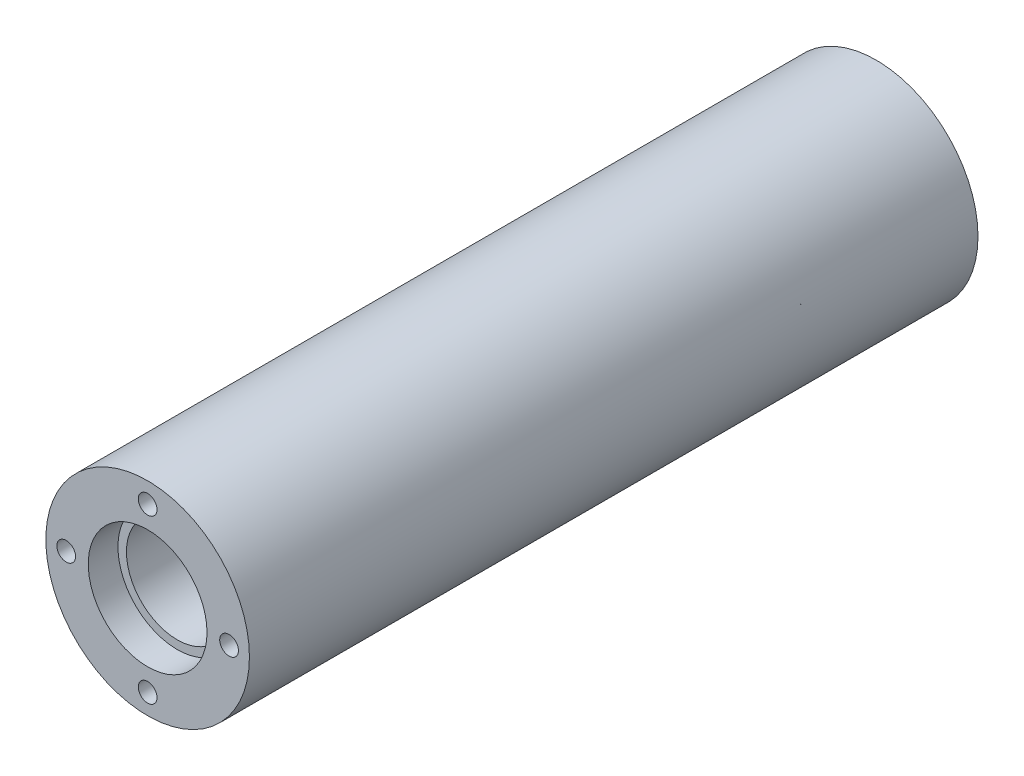
from build123d import *

# Parameters (mm, degrees)
SKETCH1_R           = 19.05
SKETCH1_R_2         = 9.525
BOSS_EXTRUDE1_DEPTH = 136.3472
SKETCH2_R           = 1.7526
CUT_EXTRUDE1_DEPTH  = 9.525
SKETCH3_R           = 1.7526
CUT_EXTRUDE2_DEPTH  = 9.525
SKETCH6_R           = 11.1125
CUT_EXTRUDE3_DEPTH  = 5.55625
SKETCH7_R           = 11.1125
CUT_EXTRUDE4_DEPTH  = 5.55625


with BuildPart() as part:
    # Sketch1 → Boss-Extrude1 (new body)
    with BuildSketch(Plane.XY):
        Circle(SKETCH1_R)
        Circle(SKETCH1_R_2, mode=Mode.SUBTRACT)
    extrude(amount=BOSS_EXTRUDE1_DEPTH)

    # Sketch2 → Cut-Extrude1 (cut)
    with BuildSketch(Plane(origin=(0, 0, 0), x_dir=(-1, 0, 0), z_dir=(0, 0, -1))):
        with Locations((0, 15.24)):
            Circle(SKETCH2_R)
        with Locations((15.24, 0)):
            Circle(SKETCH2_R)
        with Locations((0, -15.24)):
            Circle(SKETCH2_R)
        with Locations((-15.24, 0)):
            Circle(SKETCH2_R)
    extrude(amount=-CUT_EXTRUDE1_DEPTH, mode=Mode.SUBTRACT)

    # Sketch3 → Cut-Extrude2 (cut)
    with BuildSketch(Plane.XY.offset(136.3472)):
        with Locations((0, 15.24)):
            Circle(SKETCH3_R)
        with Locations((15.24, 0)):
            Circle(SKETCH3_R)
        with Locations((0, -15.24)):
            Circle(SKETCH3_R)
        with Locations((-15.24, 0)):
            Circle(SKETCH3_R)
    extrude(amount=-CUT_EXTRUDE2_DEPTH, mode=Mode.SUBTRACT)

    # Sketch6 → Cut-Extrude3 (cut)
    with BuildSketch(Plane.XY.offset(136.3472)):
        Circle(SKETCH6_R)
    extrude(amount=-CUT_EXTRUDE3_DEPTH, mode=Mode.SUBTRACT)

    # Sketch7 → Cut-Extrude4 (cut)
    with BuildSketch(Plane(origin=(0, 0, 0), x_dir=(-1, 0, 0), z_dir=(0, 0, -1))):
        Circle(SKETCH7_R)
    extrude(amount=-CUT_EXTRUDE4_DEPTH, mode=Mode.SUBTRACT)


solid = part.part
